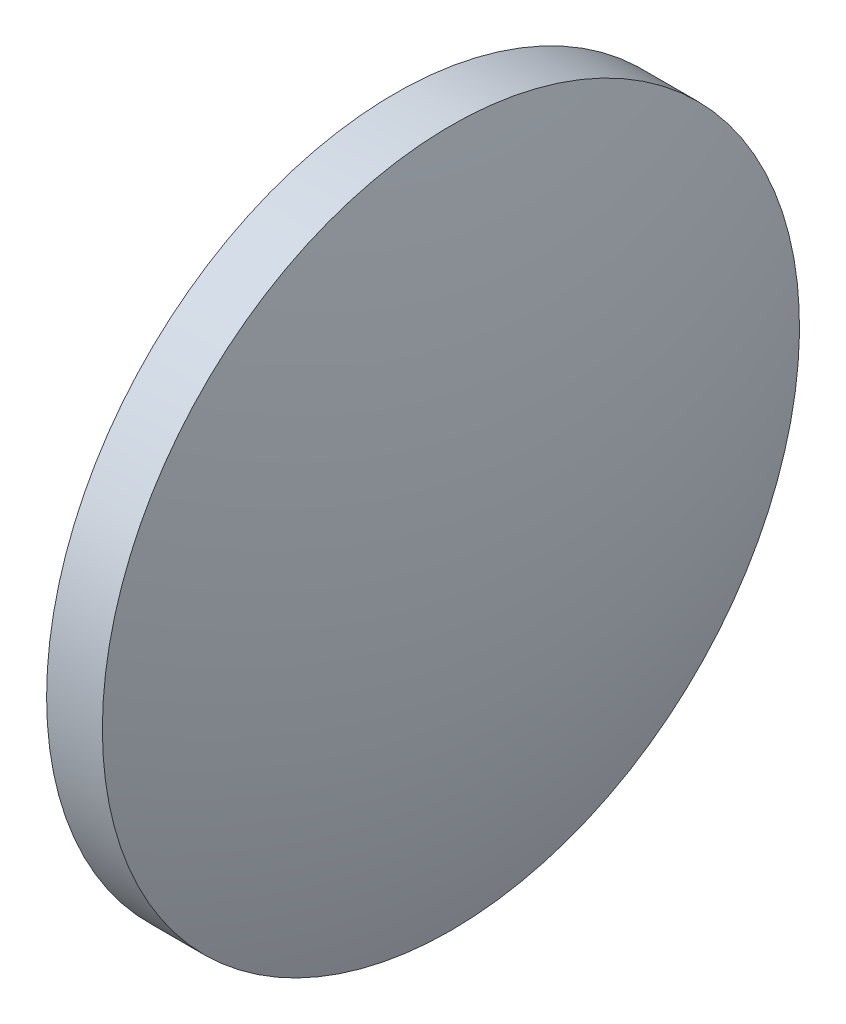
from build123d import *


with BuildPart() as part:
    # 草图1 → 旋转2 (revolve)
    with BuildSketch(Plane.XY, mode=Mode.PRIVATE) as revolve_2_sk:
        with BuildLine():
            Line((850.195901324, 251.606730537), (846.255901324, 251.606730537))
            Line((846.255901324, 251.606730537), (846.255901324, 264.106730537))
            Line((846.255901324, 264.106730537), (848.255901324, 264.106730537))
            ThreePointArc((848.255901324, 264.106730537), (849.708015423, 257.931554645), (850.195901324, 251.606730537))
        make_face()
    revolve(revolve_2_sk.sketch.rotate(Axis((843.890285421, 251.606730537, 0), (1, 0, 0)), 180), axis=Axis((843.890285421, 251.606730537, 0), (1, 0, 0)))  # turned: the seam where the file's is


solid = part.part
